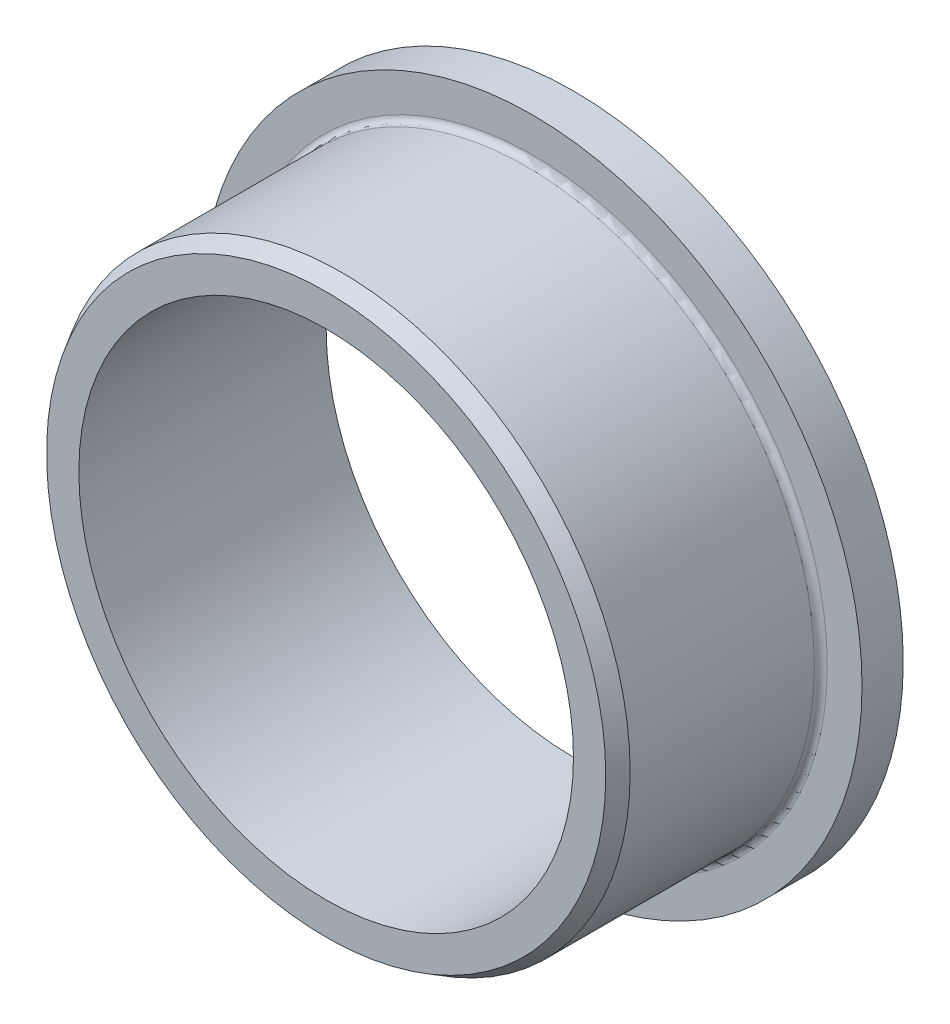
from build123d import *


with BuildPart() as part:
    # Sketch1 → Revolve1 (revolve)
    with BuildSketch(Plane(origin=(0, 0, 0), x_dir=(1, 0, 0), z_dir=(0, 1, 0))):
        with BuildLine():
            Line((25.4, 0), (19.05, 0))
            Line((19.05, 0), (19.05, -19.05))
            Line((19.05, -19.05), (21.535759249, -19.05))
            Line((21.535759249, -19.05), (22.225, -17.8562))
            Line((22.225, -17.8562), (22.225, -3.675))
            ThreePointArc((22.225, -3.675), (22.371446609, -3.321446609), (22.725, -3.175))
            Line((22.725, -3.175), (25.4, -3.175))
            Line((25.4, -3.175), (25.4, 0))
        make_face()
    revolve(axis=Axis((0, 0, 0), (0, 0, 1)))


solid = part.part
